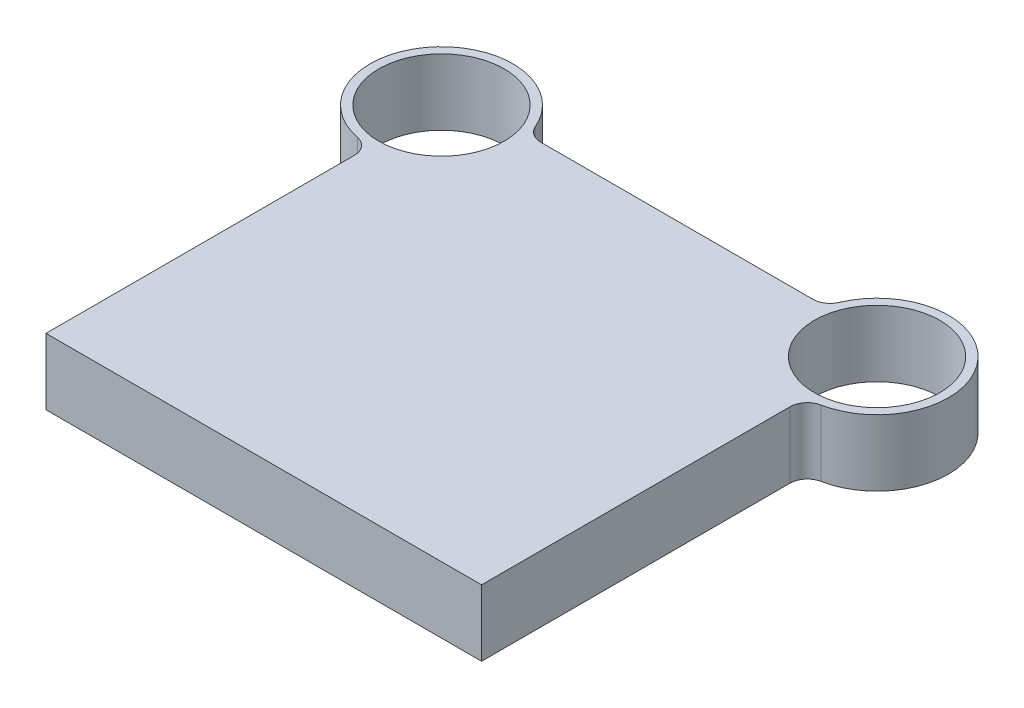
from build123d import *

# Parameters (mm, degrees)
SKETCH1_R           = 36
BOSS_EXTRUDE1_DEPTH = 38
FILLET1_R           = 10


with BuildPart() as part:
    # Sketch1 → Boss-Extrude1 (new body)
    with BuildSketch(Plane(origin=(0, 0, 0), x_dir=(1, 0, 0), z_dir=(0, 1, 0))):
        with BuildLine():
            Line((125, 0), (-125, 0))
            Line((-125, 0), (-125, 186))
            ThreePointArc((-125, 186), (-157.334192428, 252.209125332), (-85.238209296, 237))
            Line((-85.238209296, 237), (85.238209296, 237))
            ThreePointArc((85.238209296, 237), (157.334192428, 252.209125332), (125, 186))
            Line((125, 186), (125, 0))
        make_face()
        with Locations((-125, 227)):
            Circle(SKETCH1_R, mode=Mode.SUBTRACT)
        with Locations((125, 227)):
            Circle(SKETCH1_R, mode=Mode.SUBTRACT)
    extrude(amount=BOSS_EXTRUDE1_DEPTH)

    # Fillet1
    fillet1_edges = [part.edges().sort_by_distance(p)[0] for p in [
        (-125, 19, -186),
        (-85.238209296, 19, -237),
        (85.238209296, 19, -237),
        (125, 19, -186),
    ]]
    fillet(fillet1_edges, radius=FILLET1_R)


solid = part.part
